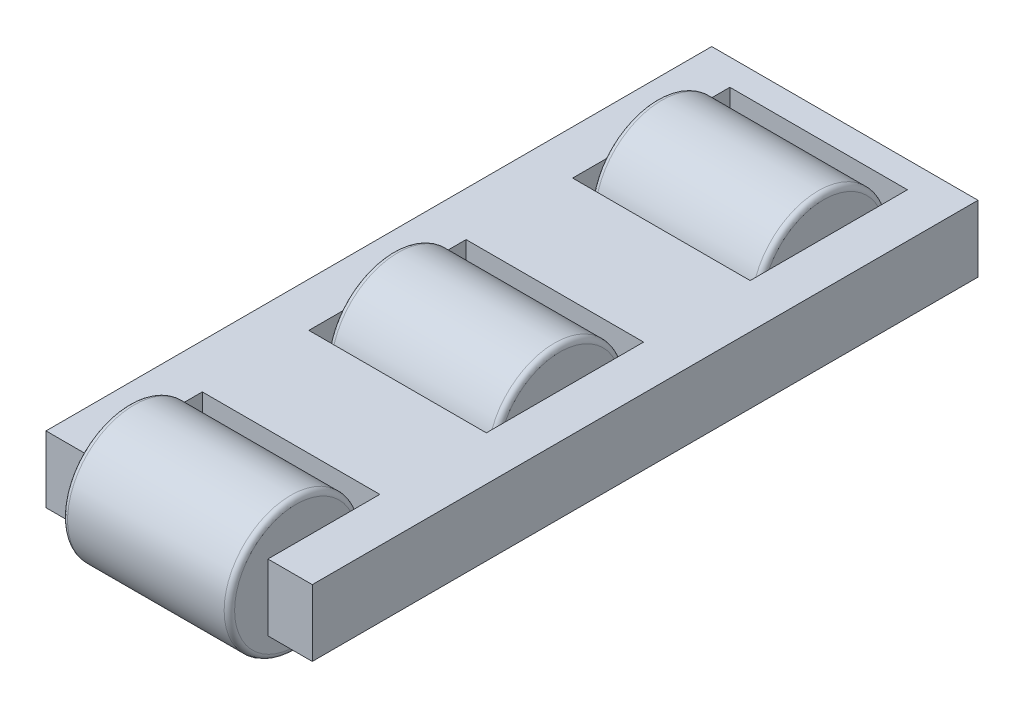
from build123d import *

# Parameters (mm, degrees)
SKETCH1_W             = 50.8
SKETCH1_H             = 127
BOSS_EXTRUDE1_DEPTH   = 12.7
SKETCH3_W             = 33.866666666
SKETCH3_H             = 21.35
SKETCH3_H_2           = 30
CUT_EXTRUDE1_DEPTH    = 12.7
SKETCH5_R             = 12.7
BOSS_EXTRUDE2_DEPTH   = 31.866667
BOSS_EXTRUDE2_2_DEPTH = 31.866667
BOSS_EXTRUDE2_3_DEPTH = 31.866667
FILLET1_R             = 1
FILLET2_R             = 1
FILLET3_R             = 1


with BuildPart() as part:
    # Sketch1 → Boss-Extrude1 (new body)
    with BuildSketch(Plane(origin=(0, 0, 0), x_dir=(1, 0, 0), z_dir=(0, 1, 0))):
        Rectangle(SKETCH1_W, SKETCH1_H)
    extrude(amount=BOSS_EXTRUDE1_DEPTH)

    # Sketch3 → Cut-Extrude1 (cut)
    with BuildSketch(Plane(origin=(0, 12.7, 0), x_dir=(1, 0, 0), z_dir=(0, 1, 0))):
        with Locations((0, -52.825)):
            Rectangle(SKETCH3_W, SKETCH3_H)
        with Locations((0, -6.825)):
            Rectangle(SKETCH3_W, SKETCH3_H_2)
        with Locations((0, 43.5)):
            Rectangle(SKETCH3_W, SKETCH3_H_2)
    extrude(amount=-CUT_EXTRUDE1_DEPTH, mode=Mode.SUBTRACT)


with BuildPart() as body_2:
    # Sketch5 → Boss-Extrude2 (new body)
    with BuildSketch(Plane.ZY.offset(-15.933333333)):
        with Locations((6.825, 6.35)):
            Circle(SKETCH5_R)
    extrude(amount=BOSS_EXTRUDE2_DEPTH)

    # Fillet1
    fillet1_edges = [body_2.edges().sort_by_distance(p)[0] for p in [
        (15.933333333, 6.35, -5.875),
        (-15.933333667, 6.35, -5.875),
    ]]
    fillet(fillet1_edges, radius=FILLET1_R)


with BuildPart() as body_3:
    # Sketch5 → Boss-Extrude2 2 (new body)
    with BuildSketch(Plane.ZY.offset(-15.933333333)):
        with Locations((-43.5, 6.35)):
            Circle(SKETCH5_R)
    extrude(amount=BOSS_EXTRUDE2_2_DEPTH)

    # Fillet2
    fillet2_edges = [body_3.edges().sort_by_distance(p)[0] for p in [
        (15.933333333, 6.35, -56.2),
        (-15.933333667, 6.35, -56.2),
    ]]
    fillet(fillet2_edges, radius=FILLET2_R)


with BuildPart() as body_4:
    # Sketch5 → Boss-Extrude2 3 (new body)
    with BuildSketch(Plane.ZY.offset(-15.933333333)):
        with Locations((57.15, 6.35)):
            Circle(SKETCH5_R)
    extrude(amount=BOSS_EXTRUDE2_3_DEPTH)

    # Fillet3
    fillet3_edges = [body_4.edges().sort_by_distance(p)[0] for p in [
        (15.933333333, 6.35, 44.45),
        (-15.933333667, 6.35, 44.45),
    ]]
    fillet(fillet3_edges, radius=FILLET3_R)


solid = Compound([part.part, body_2.part, body_3.part, body_4.part])
